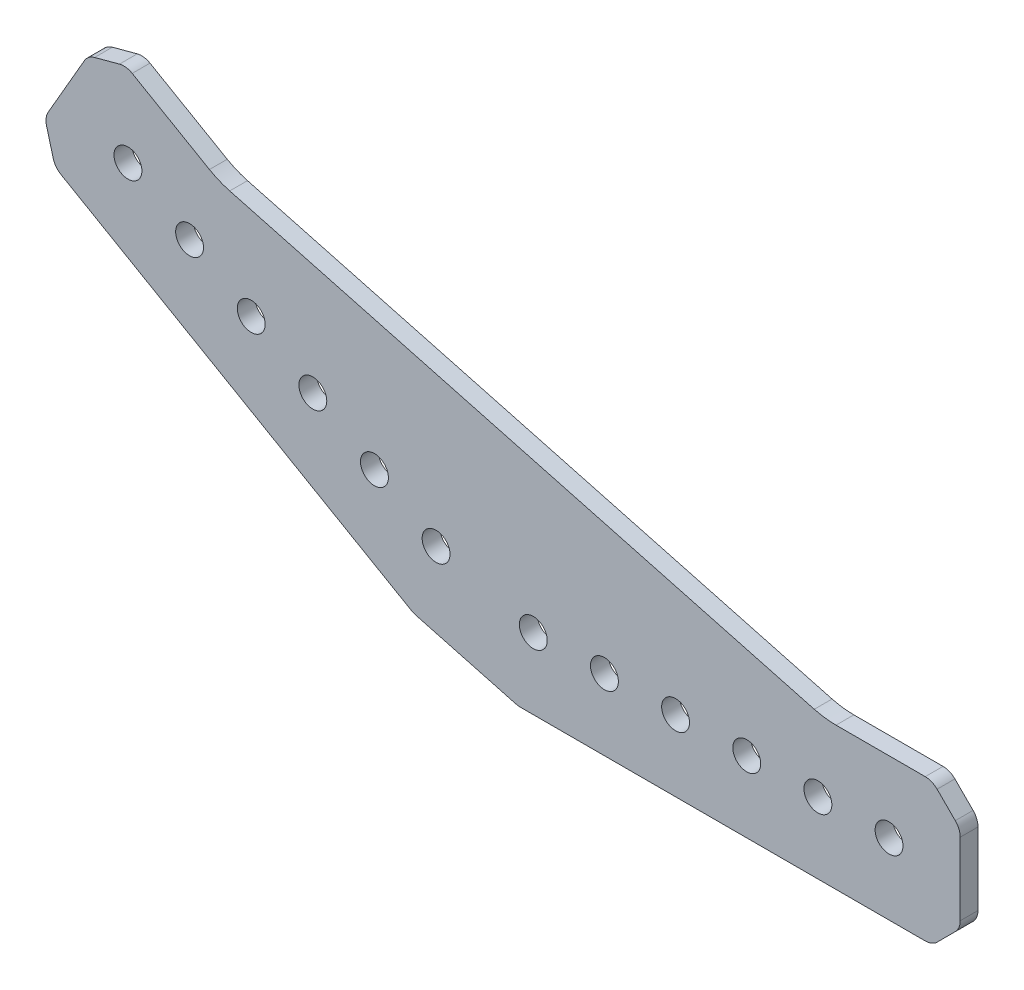
from build123d import *

# Parameters (mm, degrees)
SKETCH1_R           = 2.4892
BOSS_EXTRUDE1_DEPTH = 3.175


with BuildPart() as part:
    # Sketch1 → Boss-Extrude1 (new body)
    with BuildSketch(Plane(origin=(0, 0, 0), x_dir=(-1, 0, 0), z_dir=(0, 0, -1))):
        with BuildLine():
            Line((-82.657359313, 0), (-10.394957493, 0))
            ThreePointArc((-10.394957493, 0), (-10.003378916, 0.025665416), (-9.618500357, 0.102222521))
            Line((-9.618500357, 0.102222521), (8.278754395, 4.897777479))
            ThreePointArc((8.278754395, 4.897777479), (8.650347557, 5.02391636), (9.00229726, 5.197478746))
            Line((9.00229726, 5.197478746), (71.583372975, 41.328679656))
            ThreePointArc((71.583372975, 41.328679656), (72.463432996, 42.100471581), (72.981150454, 43.150298732))
            Line((72.981150454, 43.150298732), (74.16803932, 47.579828286))
            ThreePointArc((74.16803932, 47.579828286), (74.244596426, 48.747863998), (73.868338053, 49.856285422))
            Line((73.868338053, 49.856285422), (67.41097874, 61.040759834))
            ThreePointArc((67.41097874, 61.040759834), (66.639186816, 61.920819855), (65.589359664, 62.438537313))
            Line((65.589359664, 62.438537313), (61.15983011, 63.62542618))
            ThreePointArc((61.15983011, 63.62542618), (59.991794398, 63.701983285), (58.883372975, 63.325724913))
            Line((58.883372975, 63.325724913), (45.095284847, 55.365168521))
            ThreePointArc((45.095284847, 55.365168521), (43.335536333, 54.49735659), (41.477570524, 53.866662183))
            Line((41.477570524, 53.866662183), (-62.853960852, 25.911112606))
            ThreePointArc((-62.853960852, 25.911112606), (-64.778353646, 25.528327079), (-66.736246529, 25.4))
            Line((-66.736246529, 25.4), (-82.657359313, 25.4))
            ThreePointArc((-82.657359313, 25.4), (-83.80540961, 25.171638598), (-84.778679656, 24.521320344))
            Line((-84.778679656, 24.521320344), (-88.021320344, 21.278679656))
            ThreePointArc((-88.021320344, 21.278679656), (-88.671638598, 20.30540961), (-88.9, 19.157359313))
            Line((-88.9, 19.157359313), (-88.9, 6.242640687))
            ThreePointArc((-88.9, 6.242640687), (-88.671638598, 5.09459039), (-88.021320344, 4.121320344))
            Line((-88.021320344, 4.121320344), (-84.778679656, 0.878679656))
            ThreePointArc((-84.778679656, 0.878679656), (-83.80540961, 0.228361402), (-82.657359313, 0))
        make_face()
        with Locations((-12.7, 12.7)):
            Circle(SKETCH1_R, mode=Mode.SUBTRACT)
        with Locations((4.648522628, 17.348522628)):
            Circle(SKETCH1_R, mode=Mode.SUBTRACT)
        with Locations((-63.5, 12.7)):
            Circle(SKETCH1_R, mode=Mode.SUBTRACT)
        with Locations((-38.1, 12.7)):
            Circle(SKETCH1_R, mode=Mode.SUBTRACT)
        with Locations((26.645567884, 30.048522628)):
            Circle(SKETCH1_R, mode=Mode.SUBTRACT)
        with Locations((48.64261314, 42.748522628)):
            Circle(SKETCH1_R, mode=Mode.SUBTRACT)
        with Locations((-76.2, 12.7)):
            Circle(SKETCH1_R, mode=Mode.SUBTRACT)
        with Locations((-50.8, 12.7)):
            Circle(SKETCH1_R, mode=Mode.SUBTRACT)
        with Locations((-25.4, 12.7)):
            Circle(SKETCH1_R, mode=Mode.SUBTRACT)
        with Locations((15.647045256, 23.698522628)):
            Circle(SKETCH1_R, mode=Mode.SUBTRACT)
        with Locations((37.644090512, 36.398522628)):
            Circle(SKETCH1_R, mode=Mode.SUBTRACT)
        with Locations((59.641135768, 49.098522628)):
            Circle(SKETCH1_R, mode=Mode.SUBTRACT)
    extrude(amount=-BOSS_EXTRUDE1_DEPTH)


solid = part.part
